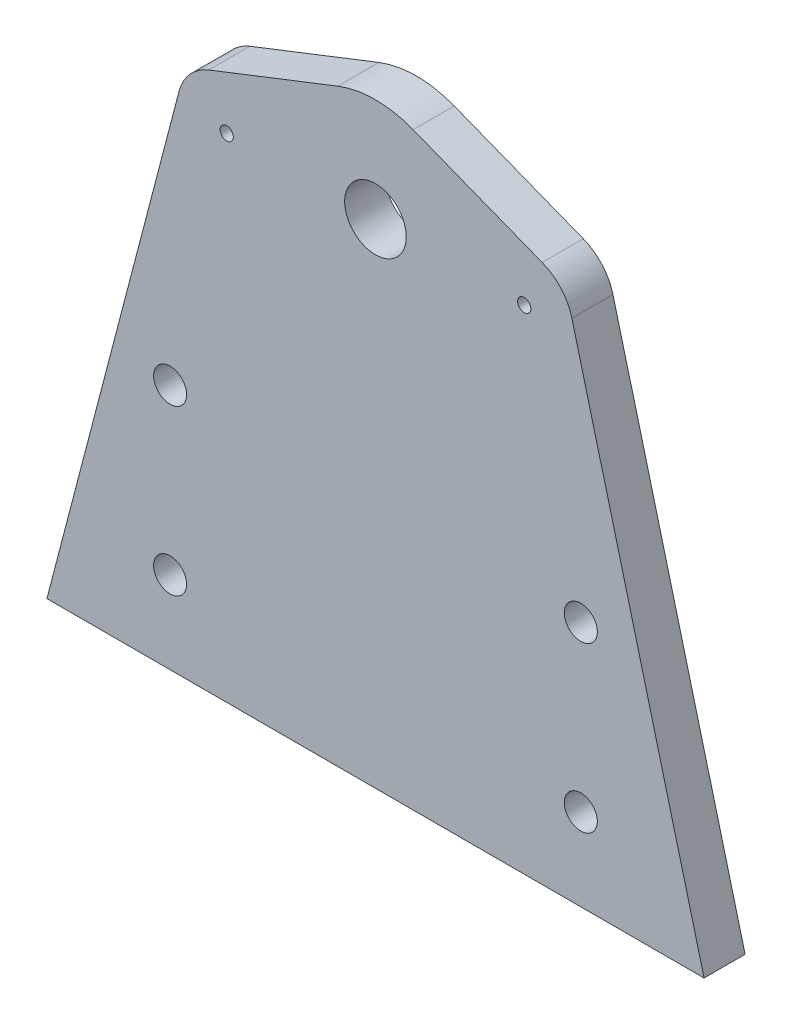
from build123d import *

# Parameters (mm, degrees)
SKETCH1_R                = 4.7625
SKETCH1_R_2              = 1.5875
BOSS_EXTRUDE1_DEPTH      = 6.35
M2_5X0_45_TAPPED_HOLE1_D = 2.05
F_1_4_20_TAPPED_HOLE1_D  = 5.1054


with BuildPart() as part:
    # Sketch1 → Boss-Extrude1 (new body)
    with BuildSketch(Plane.XY):
        with BuildLine():
            Line((-25.776330412, 7.096223594), (-5.829565224, 14.900207022))
            ThreePointArc((-5.829565224, 14.900207022), (0, 16), (5.829565224, 14.900207022))
            Line((5.829565224, 14.900207022), (25.776330412, 7.096223594))
            ThreePointArc((25.776330412, 7.096223594), (28.694445061, 5.063367965), (30.372165524, 1.92758271))
            Line((30.372165524, 1.92758271), (50.8, -76.2))
            Line((50.8, -76.2), (-50.8, -76.2))
            Line((-50.8, -76.2), (-30.372165524, 1.92758271))
            ThreePointArc((-30.372165524, 1.92758271), (-28.694445061, 5.063367965), (-25.776330412, 7.096223594))
        make_face()
        Circle(SKETCH1_R, mode=Mode.SUBTRACT)
        with Locations((-31.75, -38.1)):
            Circle(SKETCH1_R_2, mode=Mode.SUBTRACT)
        with Locations((31.75, -38.1)):
            Circle(SKETCH1_R_2, mode=Mode.SUBTRACT)
        with Locations((-31.75, -63.5)):
            Circle(SKETCH1_R_2, mode=Mode.SUBTRACT)
        with Locations((31.75, -63.5)):
            Circle(SKETCH1_R_2, mode=Mode.SUBTRACT)
    extrude(amount=BOSS_EXTRUDE1_DEPTH)

    # M2.5x0.45 Tapped Hole1 (through all)
    with Locations(Plane(origin=(0, 0, 0), x_dir=(-1, 0, 0), z_dir=(0, 0, -1))):
        with Locations((-22.999999974, 0), (22.999999974, 0)):
            Hole(M2_5X0_45_TAPPED_HOLE1_D / 2)

    # 1/4-20 Tapped Hole1 (through all)
    with Locations(Plane.XY.offset(6.35)):
        with Locations((-31.75, -38.1), (-31.75, -63.5), (31.75, -63.5), (31.75, -38.1)):
            Hole(F_1_4_20_TAPPED_HOLE1_D / 2)


solid = part.part
